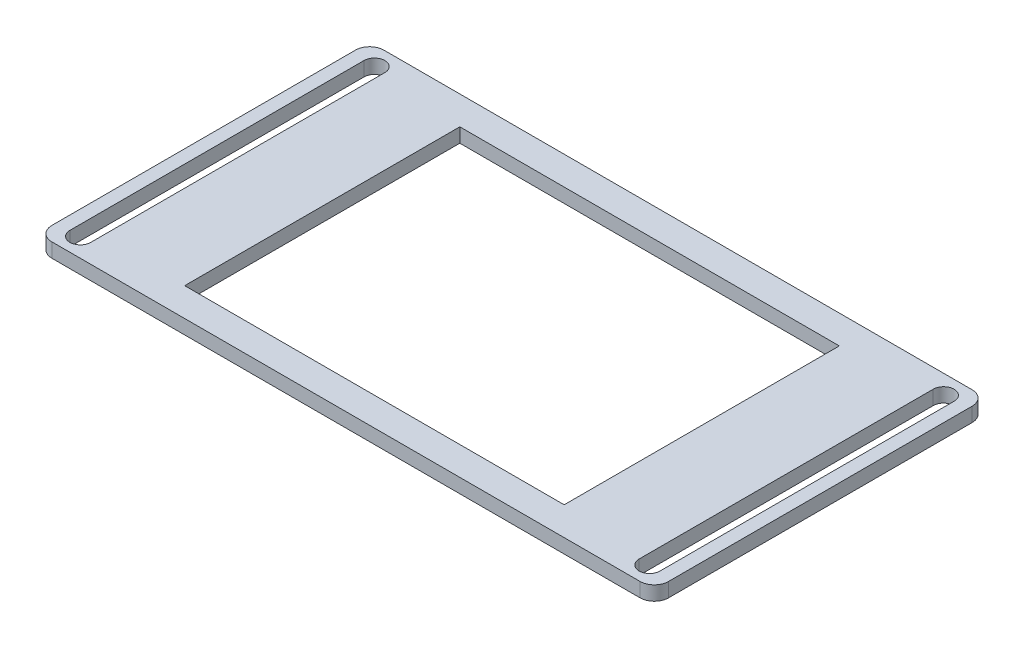
from build123d import *

# Parameters (mm, degrees)
SKETCH1_W           = 65
SKETCH1_H           = 35
SKETCH1_W_2         = 40
SKETCH1_H_2         = 29
BOSS_EXTRUDE1_DEPTH = 1.5
CUT_EXTRUDE1_DEPTH  = 2.5
FILLET2_R           = 1.5


with BuildPart() as part:
    # Sketch1 → Boss-Extrude1 (new body)
    with BuildSketch(Plane(origin=(0, 0, 0), x_dir=(1, 0, 0), z_dir=(0, 1, 0))):
        Rectangle(SKETCH1_W, SKETCH1_H)
        Rectangle(SKETCH1_W_2, SKETCH1_H_2, mode=Mode.SUBTRACT)
    extrude(amount=BOSS_EXTRUDE1_DEPTH)

    # Sketch2 → Cut-Extrude1 (cut, through all)
    with BuildSketch(Plane(origin=(0, 1.5, 0), x_dir=(1, 0, 0), z_dir=(0, 1, 0))):
        with BuildLine():
            Line((-31.1, -15.5), (-31.1, 15.5))
            ThreePointArc((-31.1, 15.5), (-30, 16.6), (-28.9, 15.5))
            Line((-28.9, 15.5), (-28.9, -15.5))
            ThreePointArc((-28.9, -15.5), (-30, -16.6), (-31.1, -15.5))
        make_face()
        with BuildLine():
            Line((31.1, -15.5), (31.1, 15.5))
            ThreePointArc((31.1, 15.5), (30, 16.6), (28.9, 15.5))
            Line((28.9, 15.5), (28.9, -15.5))
            ThreePointArc((28.9, -15.5), (30, -16.6), (31.1, -15.5))
        make_face()
    extrude(amount=-CUT_EXTRUDE1_DEPTH, mode=Mode.SUBTRACT)

    # Fillet2
    fillet2_edges = [part.edges().sort_by_distance(p)[0] for p in [
        (32.5, 0.75, 17.5),
        (-32.5, 0.75, 17.5),
        (-32.5, 0.75, -17.5),
        (32.5, 0.75, -17.5),
    ]]
    fillet(fillet2_edges, radius=FILLET2_R)


solid = part.part
